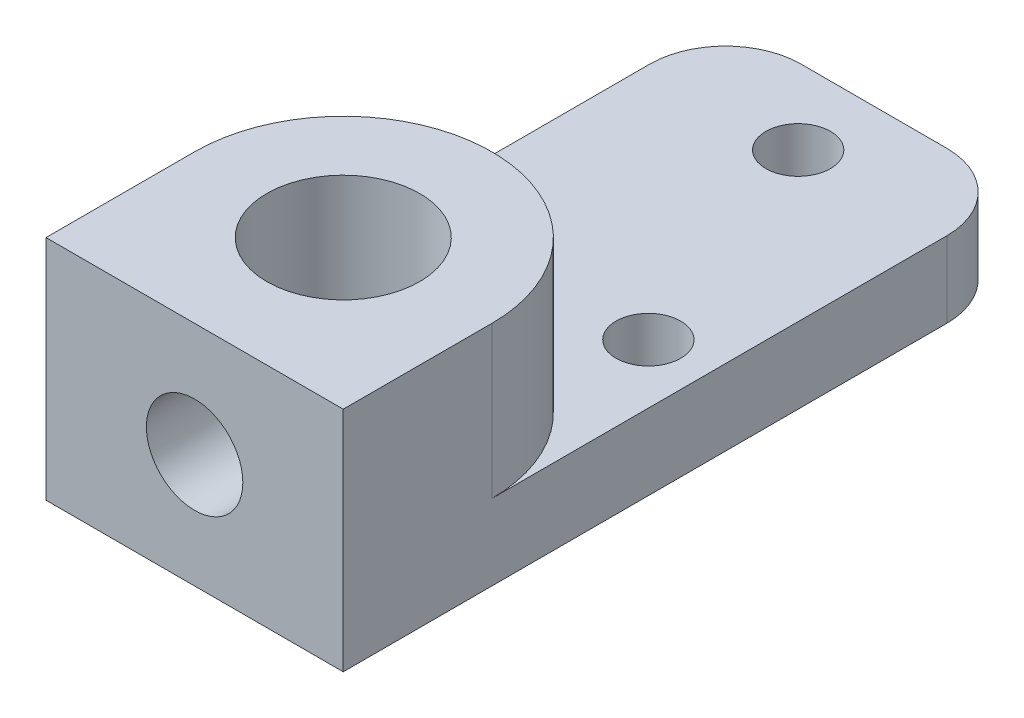
from build123d import *

# Parameters (mm, degrees)
SKETCH_1_W                = 12.446
SKETCH_1_H                = 28.448
EXTRUDE_1_DEPTH           = 9.525
CUT_EXTRUDE_1_DEPTH       = 6.35
HOLE_WIZARD_M2_5_1_D      = 2.7051
HOLE_WIZARD_M2_5_1_DEPTH  = 9.525
HOLE_WIZARD_M6_1_D        = 6.4008
HOLE_WIZARD_M3_5_1_REACH  = 48.703
HOLE_WIZARD_M3_5_1_BORE_R = 2.0193
FILLET_1_R                = 3.175


with BuildPart() as part:
    # 草图1 → 凸台-拉伸1 (new body)
    with BuildSketch(Plane(origin=(0, 36.5125, 0), x_dir=(1, 0, 0), z_dir=(0, 1, 0))):
        with Locations((0, 8.001)):
            Rectangle(SKETCH_1_W, SKETCH_1_H)
    extrude(amount=-EXTRUDE_1_DEPTH)

    # 草图2 → 切除-拉伸1 (cut)
    with BuildSketch(Plane(origin=(0, 36.5125, 0), x_dir=(-1, 0, 0), z_dir=(0, 1, 0))):
        with BuildLine():
            Line((6.223, -22.225), (6.223, 0))
            ThreePointArc((6.223, 0), (0, -6.223), (-6.223, 0))
            Line((-6.223, 0), (-6.223, -22.225))
            Line((-6.223, -22.225), (6.223, -22.225))
        make_face()
    extrude(amount=-CUT_EXTRUDE_1_DEPTH, mode=Mode.SUBTRACT)

    # M2.5 间隙孔1
    with Locations(Plane(origin=(0, 26.9875, 0), x_dir=(-1, 0, 0), z_dir=(0, -1, 0))):
        with Locations((-3.742261285, 9.034617948), (3.742261285, 9.034617948), (0, 19.05)):
            Hole(HOLE_WIZARD_M2_5_1_D / 2, depth=HOLE_WIZARD_M2_5_1_DEPTH)

    # M6 间隙孔1 (through all)
    with Locations(Plane(origin=(0, 36.5125, 0), x_dir=(1, 0, 0), z_dir=(0, 1, 0))):
        with Locations((0, 0)):
            Hole(HOLE_WIZARD_M6_1_D / 2)

    # M3.5 间隙孔1 bore → M3.5 间隙孔1 (cut, up to next)
    with BuildSketch(Plane.XY.offset(6.223), mode=Mode.PRIVATE) as hole_wizard_m3_5_1_sk1:
        with Locations((0, 31.75)):
            Circle(HOLE_WIZARD_M3_5_1_BORE_R)
    hole_wizard_m3_5_1_tool1 = extrude(hole_wizard_m3_5_1_sk1.sketch, amount=-HOLE_WIZARD_M3_5_1_REACH, mode=Mode.PRIVATE) & part.part
    add(hole_wizard_m3_5_1_tool1.solids().sort_by_distance((0, 31.75, 6.223))[0], mode=Mode.SUBTRACT)

    # 圆角1
    fillet_1_edges = [part.edges().sort_by_distance(p)[0] for p in [
        (-6.223, 28.575, -22.225),
        (6.223, 28.575, -22.225),
    ]]
    fillet(fillet_1_edges, radius=FILLET_1_R)


solid = part.part
